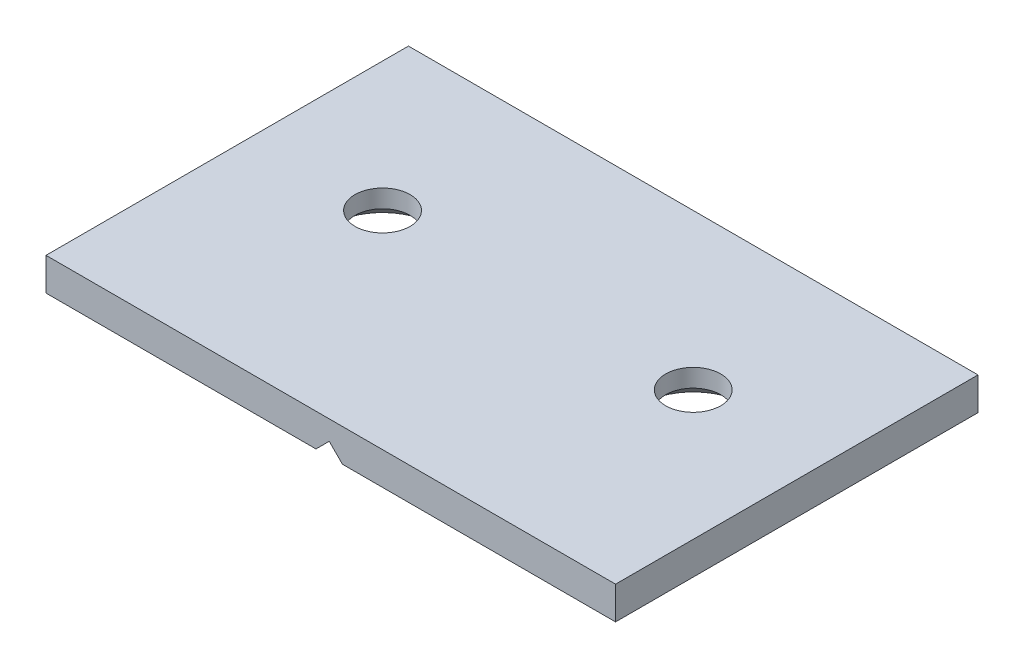
from build123d import *

# Parameters (mm, degrees)
SKETCH2_W                                           = 69.85
SKETCH2_H                                           = 44.45
BOSS_EXTRUDE1_DEPTH                                 = 4.7752
CUT_EXTRUDE1_DEPTH                                  = 1
CUT_EXTRUDE1_DEPTH_BACK                             = 45.45
CHAMFER1_SIZE                                       = 0.762
CSK_FOR_1_4_FLAT_HEAD_MACHINE_SCREW_100_D           = 6.7564
CSK_FOR_1_4_FLAT_HEAD_MACHINE_SCREW_100_DEPTH       = 4.826
CSK_FOR_1_4_FLAT_HEAD_MACHINE_SCREW_100_CSINK_D     = 12.8778
CSK_FOR_1_4_FLAT_HEAD_MACHINE_SCREW_100_CSINK_ANGLE = 100
CSK_FOR_1_4_FLAT_HEAD_MACHINE_SCREW_100_TIP         = 2.029827343


with BuildPart() as part:
    # Sketch2 → Boss-Extrude1 (new body)
    with BuildSketch(Plane(origin=(0, 0, 0), x_dir=(1, 0, 0), z_dir=(0, 1, 0))):
        with Locations((1.080982686, -0.881944444)):
            Rectangle(SKETCH2_W, SKETCH2_H)
    extrude(amount=BOSS_EXTRUDE1_DEPTH)

    # Sketch3 → Cut-Extrude1 (cut, two sides)
    with BuildSketch(Plane(origin=(0, 0, -21.343055556), x_dir=(-1, 0, 0), z_dir=(0, 0, -1))) as cut_extrude1_sk:
        Polygon((-0.888710757, 2.3876), (-3.463824269, -0.187513512), (1.686402756, -0.187513512), align=None)
    extrude(amount=CUT_EXTRUDE1_DEPTH, mode=Mode.SUBTRACT)
    extrude(cut_extrude1_sk.sketch, amount=-CUT_EXTRUDE1_DEPTH_BACK, mode=Mode.SUBTRACT)

    # Chamfer1
    chamfer1_edges = [part.edges().sort_by_distance(p)[0] for p in [
        (-17.671453278, 0, -21.343055556),
        (19.641146722, 0, 23.106944444),
        (19.641146722, 0, -21.343055556),
        (36.005982686, 0, 0.881944444),
        (-17.671453278, 0, 23.106944444),
        (-33.844017314, 0, 0.881944444),
    ]]
    chamfer(chamfer1_edges, length=CHAMFER1_SIZE)

    # CSK for 1/4 Flat Head Machine Screw (100)1
    with Locations(Plane(origin=(0, 0, 0), x_dir=(-1, 0, 0), z_dir=(0, -1, 0))):
        with Locations((-20.130982686, 2.293055556), (17.969017314, 2.293055556)):
            CounterSinkHole(CSK_FOR_1_4_FLAT_HEAD_MACHINE_SCREW_100_D / 2, CSK_FOR_1_4_FLAT_HEAD_MACHINE_SCREW_100_CSINK_D / 2, depth=CSK_FOR_1_4_FLAT_HEAD_MACHINE_SCREW_100_DEPTH, counter_sink_angle=CSK_FOR_1_4_FLAT_HEAD_MACHINE_SCREW_100_CSINK_ANGLE)
            with Locations((0, 0, -(CSK_FOR_1_4_FLAT_HEAD_MACHINE_SCREW_100_DEPTH + CSK_FOR_1_4_FLAT_HEAD_MACHINE_SCREW_100_TIP / 2))):  # 118° drill point
                Cone(0, CSK_FOR_1_4_FLAT_HEAD_MACHINE_SCREW_100_D / 2, CSK_FOR_1_4_FLAT_HEAD_MACHINE_SCREW_100_TIP, mode=Mode.SUBTRACT)


solid = part.part
